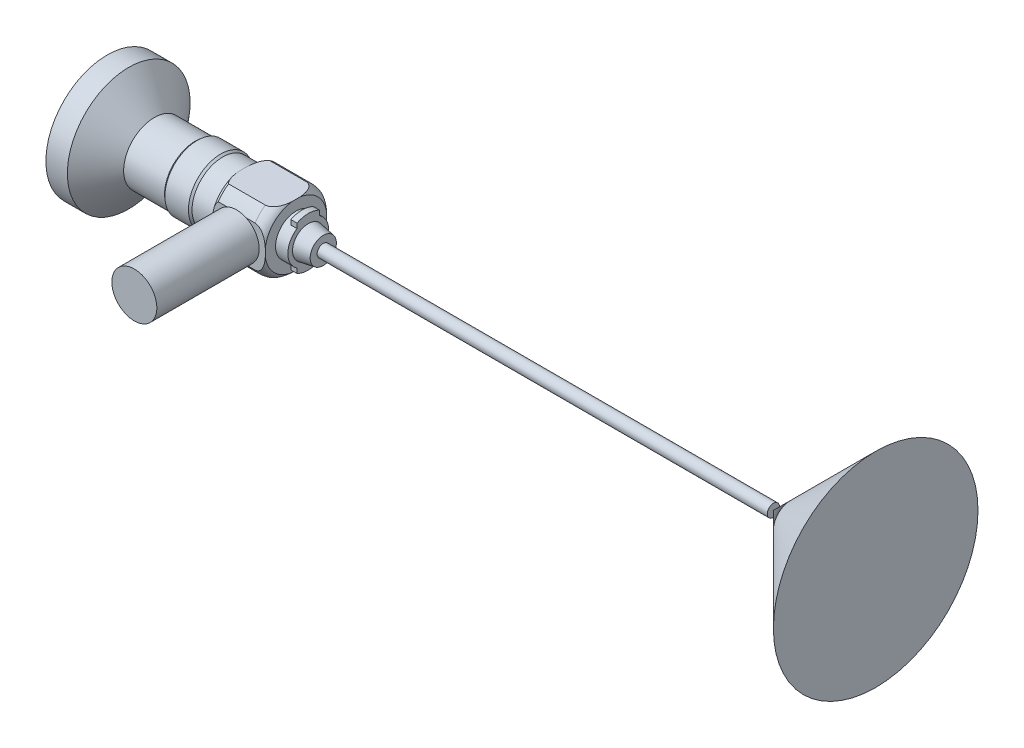
from build123d import *

# Parameters (mm, degrees)
SKETCH2_W           = 24.86541407
SKETCH2_H           = 5.423229841
SKETCH2_H_2         = 4.001260317
CUT_EXTRUDE1_DEPTH  = 15
CIRPATTERN1_COUNT   = 2
CIRPATTERN1_ANGLE   = 90
CUT_EXTRUDE2_DEPTH  = 1.5
SKETCH4_R           = 5.5
BOSS_EXTRUDE1_DEPTH = 25
SKETCH5_R           = 1.5
BOSS_EXTRUDE2_DEPTH = 110


with BuildPart() as part:
    # Sketch1 → Revolve1 (revolve)
    with BuildSketch(Plane.XY):
        with BuildLine():
            ThreePointArc((-74.569724464, 0), (-75.692690434, -7.615947487), (-77.869724464, -15))
            Line((-77.869724464, -15), (-72.619724464, -15))
            Line((-72.619724464, -15), (-66.369724464, -7.5))
            Line((-66.369724464, -7.5), (-56.369724464, -7.5))
            Line((-56.369724464, -7.5), (-55.889724464, -7.9))
            Line((-55.889724464, -7.9), (-50.139724464, -7.9))
            Line((-50.139724464, -7.9), (-49.659724464, -7.5))
            Line((-49.659724464, -7.5), (-44.659724464, -7.5))
            ThreePointArc((-44.659724464, -7.5), (-44.085344133, -8.375316627), (-43.245187811, -9))
            Line((-43.245187811, -9), (-40.559724464, -9))
            Line((-40.559724464, -9), (-34.259724464, -9))
            ThreePointArc((-34.259724464, -9), (-32.817493666, -8.603076001), (-31.746136172, -7.559154808))
            Line((-31.746136172, -7.559154808), (-31.746136172, -5))
            Line((-31.746136172, -5), (-30.246136172, -5))
            Line((-30.246136172, -5), (-30.246136172, -6))
            Line((-30.246136172, -6), (-28.746136172, -6))
            Line((-28.746136172, -6), (-28.746136172, -3.85))
            Line((-28.746136172, -3.85), (-25.083482145, -3.2))
            Line((-25.083482145, -3.2), (-25.083482145, 0))
            Line((-25.083482145, 0), (-74.569724464, 0))
        make_face()
    revolve(axis=Axis((88.99, 0, 0), (-1, 0, 0)))

    # Sketch2 → Cut-Extrude1 (cut)
    with BuildSketch(Plane(origin=(-31.746136172, 0, 0), x_dir=(0, 0, -1), z_dir=(1, 0, 0))):
        with Locations((0, -10.211614921)):
            Rectangle(SKETCH2_W, SKETCH2_H)
        with Locations((0, 9.500630158)):
            Rectangle(SKETCH2_W, SKETCH2_H_2)
    cut_extrude1 = extrude(amount=-CUT_EXTRUDE1_DEPTH, mode=Mode.SUBTRACT)

    # CirPattern1: Cut-Extrude1 ×2 about axis
    cirpattern1_axis = Axis((88.99, 0, 0), (-1, 0, 0))
    for i in range(1, CIRPATTERN1_COUNT):
        add(cut_extrude1.rotate(cirpattern1_axis, i * CIRPATTERN1_ANGLE / (CIRPATTERN1_COUNT - 1)), mode=Mode.SUBTRACT)

    # Sketch3 → Cut-Extrude2 (cut)
    with BuildSketch(Plane(origin=(-28.746136172, 0, 0), x_dir=(0, 0, -1), z_dir=(1, 0, 0))):
        with BuildLine():
            Line((2.75, -4.175823272), (2.75, -6.437196595))
            Line((2.75, -6.437196595), (5.963766818, -6.437196595))
            Line((5.963766818, -6.437196595), (6.43018781, 6.437196595))
            Line((6.43018781, 6.437196595), (2.75, 6.437196595))
            Line((2.75, 6.437196595), (2.75, 4.175823272))
            ThreePointArc((2.75, 4.175823272), (5, 0), (2.75, -4.175823272))
        make_face()
        with BuildLine():
            Line((-2.75, -6.437196595), (-2.75, -4.175823272))
            ThreePointArc((-2.75, -4.175823272), (-5, 0), (-2.75, 4.175823272))
            Line((-2.75, 4.175823272), (-2.75, 6.437196595))
            Line((-2.75, 6.437196595), (-6.280612264, 6.437196595))
            Line((-6.280612264, 6.437196595), (-6.280612264, -6.437196595))
            Line((-6.280612264, -6.437196595), (-2.75, -6.437196595))
        make_face()
    extrude(amount=-CUT_EXTRUDE2_DEPTH, mode=Mode.SUBTRACT)

    # Sketch4 → Boss-Extrude1 (add)
    with BuildSketch(Plane.XY.offset(7.5)):
        with Locations((-38.752456137, 0)):
            Circle(SKETCH4_R)
    extrude(amount=BOSS_EXTRUDE1_DEPTH)

    # Sketch5 → Boss-Extrude2 (add)
    with BuildSketch(Plane(origin=(-25.083482145, 0, 0), x_dir=(0, 0, -1), z_dir=(1, 0, 0))):
        Circle(SKETCH5_R)
    extrude(amount=BOSS_EXTRUDE2_DEPTH)


with BuildPart() as body_2:
    # Sketch6 → Revolve2 (revolve)
    with BuildSketch(Plane.XY):
        Polygon((84.916517855, 0), (109.916517855, 0), (109.916517855, -25), align=None)
    revolve(axis=Axis((84.916517855, 0, 0), (1, 0, 0)))


solid = Compound([part.part, body_2.part])
